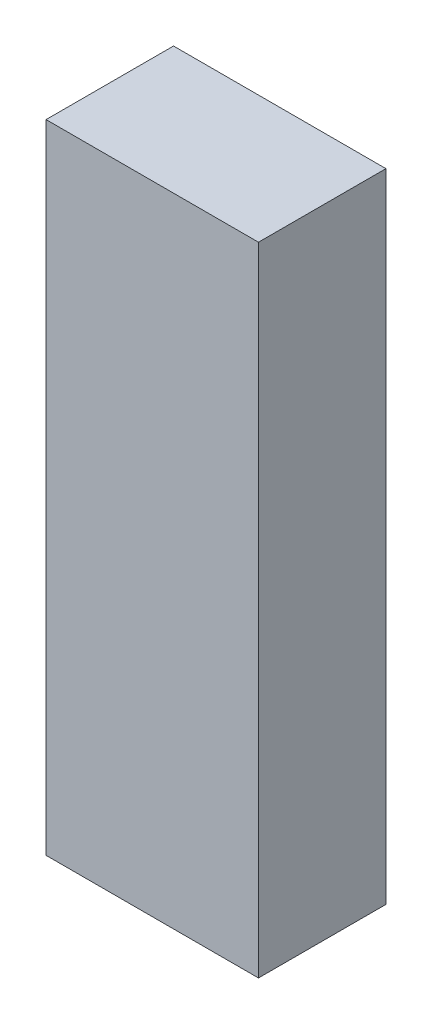
from build123d import *

# Parameters (mm, degrees)
ESQUISSE1_W        = 50
ESQUISSE1_H        = 150
BOSS_EXTRU_1_DEPTH = 30


with BuildPart() as part:
    # Esquisse1 → Boss.-Extru.1 (new body)
    with BuildSketch(Plane.XY):
        with Locations((1.19760479, -38.622754491)):
            Rectangle(ESQUISSE1_W, ESQUISSE1_H)
    extrude(amount=BOSS_EXTRU_1_DEPTH)


solid = part.part
